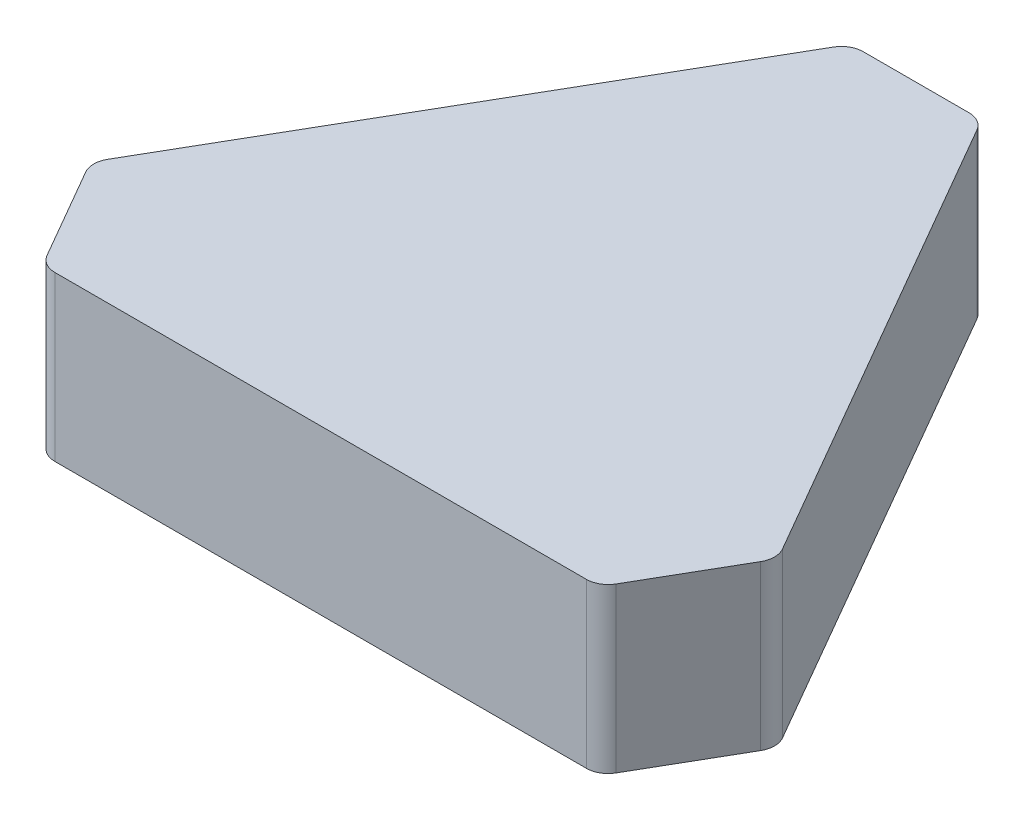
from build123d import *

# Parameters (mm, degrees)
SKETCH2_R               = 21.650635095
BOSS_EXTRUDE1_DEPTH     = 15
CUT_EXTRUDE1_DEPTH      = 1
CUT_EXTRUDE1_DEPTH_BACK = 16
FILLET1_R               = 2
SKETCH4_R               = 13.650635095
CUT_EXTRUDE2_DEPTH      = 3


with BuildPart() as part:
    # Sketch2 → Boss-Extrude1 (new body)
    with BuildSketch(Plane(origin=(0, 0, 0), x_dir=(1, 0, 0), z_dir=(0, 1, 0))):
        with Locations((37.5, 21.650635095)):
            Circle(SKETCH2_R)
        with BuildLine():
            Line((18.749999007, 32.475950921), (0, 0))
            Line((0, 0), (37.5, 0))
            ThreePointArc((37.5, 0), (18.750000497, 10.825316687), (18.749999007, 32.475950921))
        make_face()
        with BuildLine():
            Line((37.5, 64.951905284), (18.749999007, 32.475950921))
            ThreePointArc((18.749999007, 32.475950921), (37.499999914, 43.301270189), (56.250000907, 32.47595107))
            Line((56.250000907, 32.47595107), (37.5, 64.951905284))
        make_face()
        with BuildLine():
            ThreePointArc((59.150635095, 21.650635095), (52.809310892, 6.341324202), (37.5, 0))
            Line((37.5, 0), (75, 0))
            Line((75, 0), (56.250000907, 32.47595107))
            ThreePointArc((56.250000907, 32.47595107), (58.412907828, 27.254230919), (59.150635095, 21.650635095))
        make_face()
    extrude(amount=BOSS_EXTRUDE1_DEPTH)

    # Sketch3 → Cut-Extrude1 (cut, two sides)
    with BuildSketch(Plane(origin=(0, 15, 0), x_dir=(1, 0, 0), z_dir=(0, 1, 0))) as cut_extrude1_sk:
        Polygon((31.5, 54.559600438), (43.5, 54.559600438), (37.5, 64.951905284), align=None)
        Polygon((0, 0), (6, 10.392304845), (12, 0), align=None)
        Polygon((75, 0), (69, 10.392304845), (63, 0), align=None)
    extrude(amount=CUT_EXTRUDE1_DEPTH, mode=Mode.SUBTRACT)
    extrude(cut_extrude1_sk.sketch, amount=-CUT_EXTRUDE1_DEPTH_BACK, mode=Mode.SUBTRACT)

    # Fillet1
    fillet1_edges = [part.edges().sort_by_distance(p)[0] for p in [
        (31.5, 7.5, -54.559600438),
        (43.5, 7.5, -54.559600438),
        (12, 7.5, 0),
        (6, 7.5, -10.392304845),
        (63, 7.5, 0),
        (69, 7.5, -10.392304845),
    ]]
    fillet(fillet1_edges, radius=FILLET1_R)

    # Sketch4 → Cut-Extrude2 (cut)
    with BuildSketch(Plane.XZ):
        with Locations((37.5, -21.650635095)):
            Circle(SKETCH4_R)
    extrude(amount=-CUT_EXTRUDE2_DEPTH, mode=Mode.SUBTRACT)


solid = part.part
